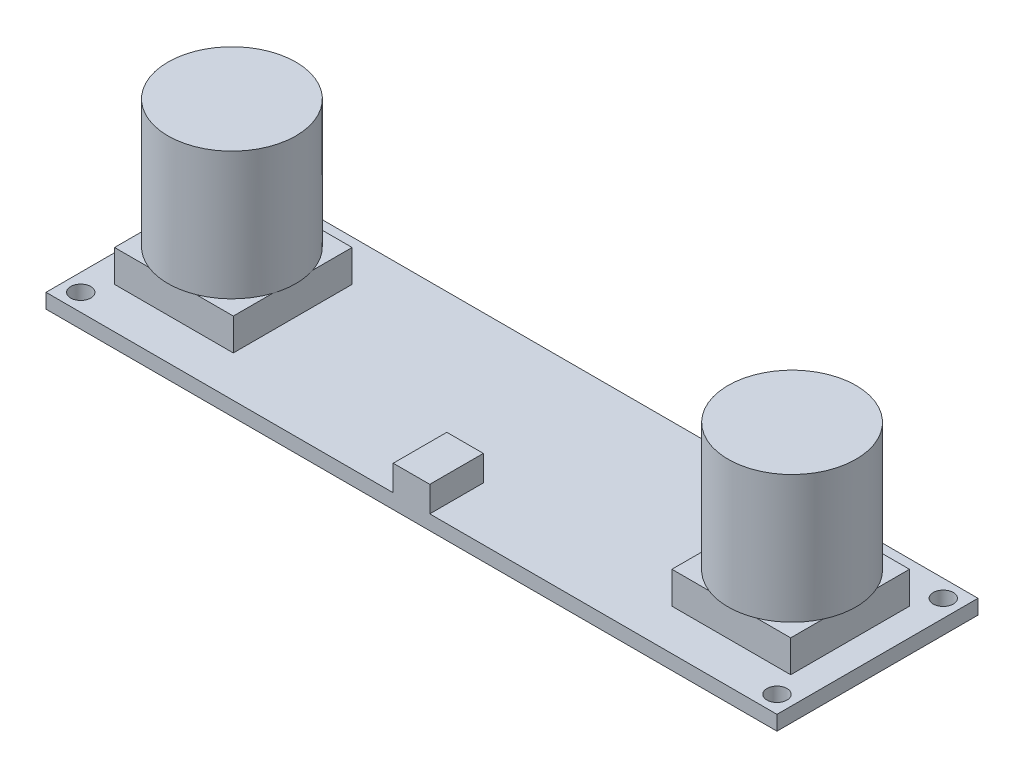
from build123d import *

# Parameters (mm, degrees)
SKETCH_1_W          = 80
SKETCH_1_H          = 22
EXTRUDE_1_DEPTH     = 1.6
SKETCH_2_W          = 13
SKETCH_2_H          = 13
EXTRUDE_2_DEPTH     = 3.5
SKETCH_4_R          = 7
EXTRUDE_3_DEPTH     = 14
SKETCH_5_R          = 1.1
CUT_EXTRUDE_1_DEPTH = 2.6
EXTRUDE_4_DEPTH     = 2.8


with BuildPart() as part:
    # 草图1 → 凸台-拉伸1 (new body)
    with BuildSketch(Plane(origin=(0, 0, 0), x_dir=(1, 0, 0), z_dir=(0, 1, 0))):
        Rectangle(SKETCH_1_W, SKETCH_1_H)
    extrude(amount=EXTRUDE_1_DEPTH)

    # 草图2 → 凸台-拉伸2 (add)
    with BuildSketch(Plane(origin=(0, 1.6, 0), x_dir=(1, 0, 0), z_dir=(0, 1, 0))):
        with Locations((30.5, 0)):
            Rectangle(SKETCH_2_W, SKETCH_2_H)
        with Locations((-30.5, 0)):
            Rectangle(SKETCH_2_W, SKETCH_2_H)
    extrude(amount=EXTRUDE_2_DEPTH)

    # 草图4 → 凸台-拉伸3 (add)
    with BuildSketch(Plane(origin=(0, 5.1, 0), x_dir=(1, 0, 0), z_dir=(0, 1, 0))):
        with Locations((-30.65, 0)):
            Circle(SKETCH_4_R)
        with Locations((30.65, 0)):
            Circle(SKETCH_4_R)
    extrude(amount=EXTRUDE_3_DEPTH)

    # 草图5 → 切除-拉伸1 (cut, through all)
    with BuildSketch(Plane(origin=(0, 1.6, 0), x_dir=(1, 0, 0), z_dir=(0, 1, 0))):
        with Locations((-38.1, 9.1)):
            Circle(SKETCH_5_R)
        with Locations((-38.1, -9.1)):
            Circle(SKETCH_5_R)
        with Locations((38.1, -9.1)):
            Circle(SKETCH_5_R)
        with Locations((38.1, 9.1)):
            Circle(SKETCH_5_R)
    extrude(amount=-CUT_EXTRUDE_1_DEPTH, mode=Mode.SUBTRACT)

    # 草图6 → 凸台-拉伸4 (add)
    with BuildSketch(Plane(origin=(0, 1.6, 0), x_dir=(1, 0, 0), z_dir=(0, 1, 0))):
        Polygon((0, -11), (-2, -11), (-2, -5.136292724), (2, -5.136292724), (2, -11), align=None)
    extrude(amount=EXTRUDE_4_DEPTH)


solid = part.part
